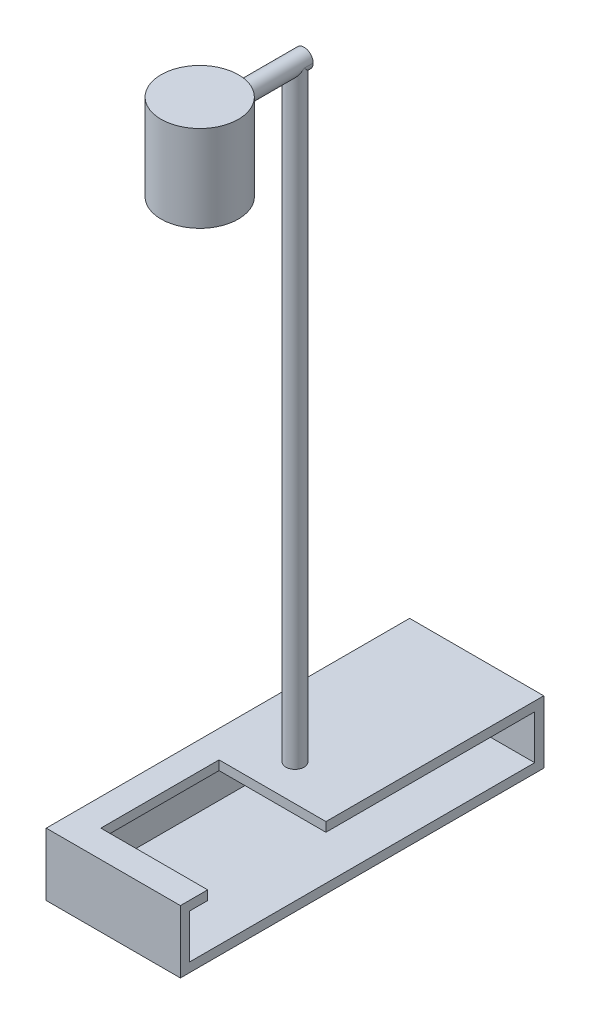
from build123d import *
from build123d.topology import SkipClean

# Parameters (mm, degrees)
SKETCH4_R           = 2
BOSS_EXTRUDE1_DEPTH = 140
SKETCH5_W           = 29.5
SKETCH5_H           = 13.79
BOSS_EXTRUDE3_DEPTH = 79.9
SKETCH6_W           = 75.9
SKETCH6_H           = 9.7
CUT_EXTRUDE1_DEPTH  = 27.5
SKETCH7_W           = 23.5
SKETCH7_H           = 26
CUT_EXTRUDE2_DEPTH  = 3
SKETCH8_R           = 2
BOSS_EXTRUDE4_DEPTH = 22.95
SKETCH12_R          = 8.5
BOSS_EXTRUDE6_DEPTH = 15.01
SKETCH13_R          = 8.5
BOSS_EXTRUDE7_DEPTH = 4
SKETCH14_R          = 6.5
CUT_EXTRUDE3_DEPTH  = 12


with BuildPart() as part:
    # Sketch4 → Boss-Extrude1 (new body)
    with BuildSketch(Plane(origin=(0, 0, 0), x_dir=(1, 0, 0), z_dir=(0, 1, 0))):
        with Locations(Location((0, -39.95, 0), (0, 0, 270))):
            Circle(SKETCH4_R)
    extrude(amount=BOSS_EXTRUDE1_DEPTH)

    # Sketch5 → Boss-Extrude3 (add)
    with BuildSketch(Plane.XY):
        Rectangle(SKETCH5_W, SKETCH5_H)
    extrude(amount=BOSS_EXTRUDE3_DEPTH)

    # Sketch6 → Cut-Extrude1 (cut)
    with BuildSketch(Plane(origin=(14.75, 0, 0), x_dir=(0, 0, -1), z_dir=(1, 0, 0))):
        with Locations((-39.95, 0)):
            Rectangle(SKETCH6_W, SKETCH6_H)
    extrude(amount=-CUT_EXTRUDE1_DEPTH, mode=Mode.SUBTRACT)

    # Sketch7 → Cut-Extrude2 (cut)
    with BuildSketch(Plane(origin=(0, 6.895, 0), x_dir=(1, 0, 0), z_dir=(0, 1, 0))):
        with Locations((3, -60.9)):
            Rectangle(SKETCH7_W, SKETCH7_H)
    extrude(amount=-CUT_EXTRUDE2_DEPTH, mode=Mode.SUBTRACT)

    # Sketch8 → Boss-Extrude4 (add)
    with SkipClean():  # the faces are left unmerged after this step: merging them gives an invalid solid
        with BuildSketch(Plane.XY.offset(37.95)):
            with Locations((0, 140)):
                Circle(SKETCH8_R)
        extrude(amount=BOSS_EXTRUDE4_DEPTH)

    # Sketch12 → Boss-Extrude6 (add)
    with SkipClean():  # the faces are left unmerged after this step: merging them gives an invalid solid
        with BuildSketch(Plane(origin=(0, 140, 0), x_dir=(1, 0, 0), z_dir=(0, 1, 0))):
            with Locations(Location((0, -60.9, 0), (0, 0, 270))):
                Circle(SKETCH12_R)
        extrude(amount=-BOSS_EXTRUDE6_DEPTH)

    # Sketch13 → Boss-Extrude7 (add)
    with SkipClean():  # the faces are left unmerged after this step: merging them gives an invalid solid
        with BuildSketch(Plane(origin=(0, 140, 0), x_dir=(1, 0, 0), z_dir=(0, 1, 0))):
            with Locations(Location((0, -60.9, 0), (0, 0, 270))):
                Circle(SKETCH13_R)
        extrude(amount=BOSS_EXTRUDE7_DEPTH)

    # Sketch14 → Cut-Extrude3 (cut)
    with SkipClean():  # the faces are left unmerged after this step: merging them gives an invalid solid
        with BuildSketch(Plane.XZ.offset(-124.99)):
            with Locations(Location((0, 60.9, 0), (0, 0, 270))):
                Circle(SKETCH14_R)
        extrude(amount=-CUT_EXTRUDE3_DEPTH, mode=Mode.SUBTRACT)


solid = part.part
